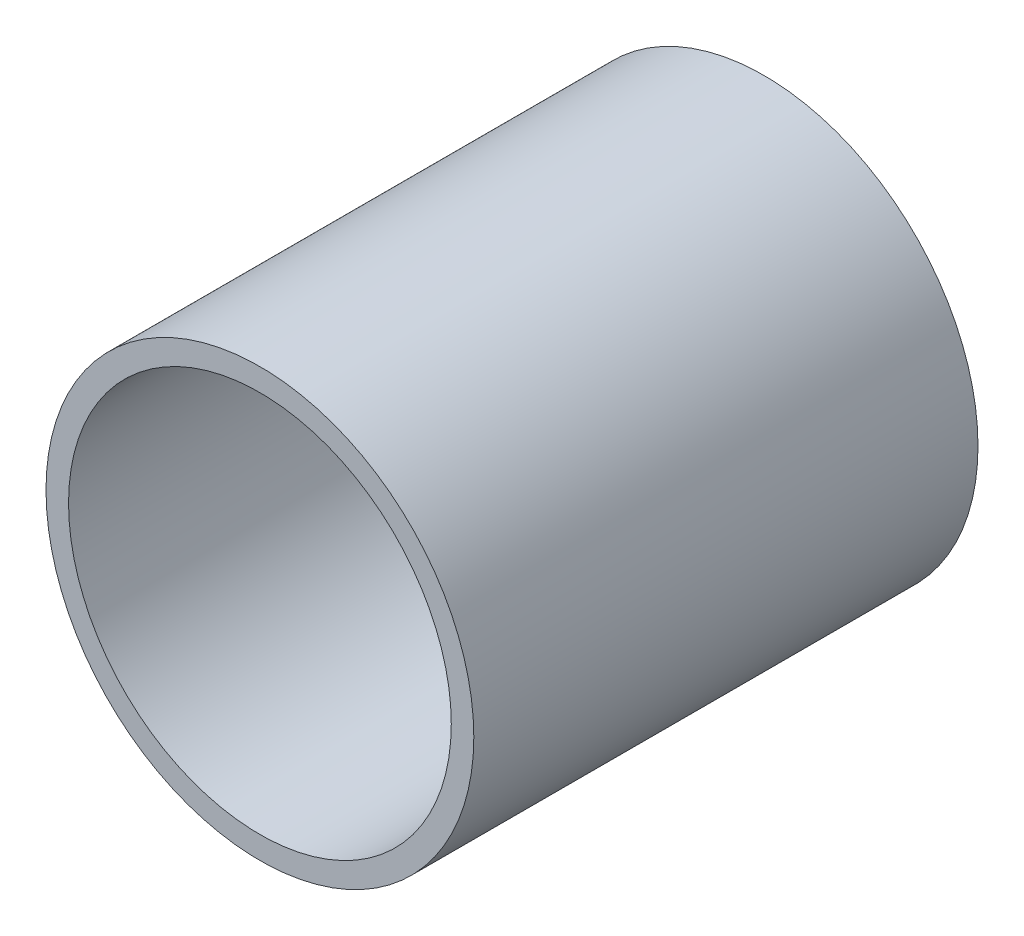
from build123d import *

# Parameters (mm, degrees)
SKETCH1_R           = 57.15
SKETCH1_R_2         = 51.1302
EXTRUDE_THIN1_DEPTH = 67.35


with BuildPart() as part:
    # Sketch1 → Extrude-Thin1 (new body, symmetric)
    with BuildSketch(Plane.XY):
        Circle(SKETCH1_R)
        Circle(SKETCH1_R_2, mode=Mode.SUBTRACT)
    extrude(amount=EXTRUDE_THIN1_DEPTH, both=True)


solid = part.part
